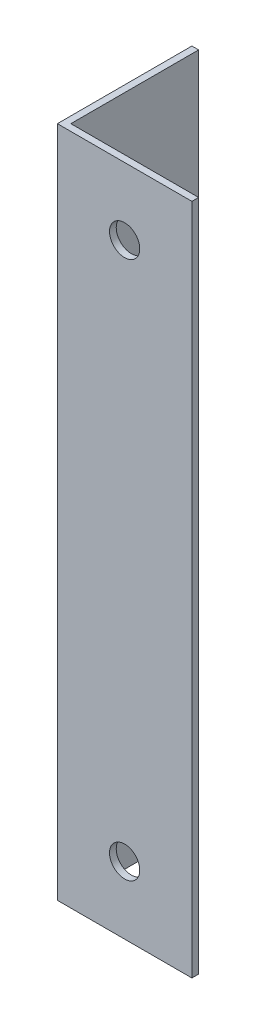
from build123d import *

# Parameters (mm, degrees)
EXTRUDE_1_DEPTH     = 100
SKETCH_2_R          = 2.25
CUT_EXTRUDE_1_DEPTH = 2
SKETCH_3_R          = 2.25
CUT_EXTRUDE_2_DEPTH = 2


with BuildPart() as part:
    # Эскиз1 → Бобышка-Вытянуть1 (new body)
    with BuildSketch(Plane(origin=(0, 0, 0), x_dir=(1, 0, 0), z_dir=(0, 1, 0))):
        Polygon((0, 0), (0, 20), (1, 20), (1, 1), (20, 1), (20, 0), align=None)
    extrude(amount=EXTRUDE_1_DEPTH)

    # Эскиз2 → Вырез-Вытянуть1 (cut, through all)
    with BuildSketch(Plane(origin=(0, 0, -1), x_dir=(-1, 0, 0), z_dir=(0, 0, -1))):
        with Locations((-10, 10)):
            Circle(SKETCH_2_R)
        with Locations((-10, 90)):
            Circle(SKETCH_2_R)
    extrude(amount=-CUT_EXTRUDE_1_DEPTH, mode=Mode.SUBTRACT)

    # Эскиз3 → Вырез-Вытянуть2 (cut, through all)
    with BuildSketch(Plane(origin=(1, 0, 0), x_dir=(0, 0, -1), z_dir=(1, 0, 0))):
        with Locations((10.5, 9.5)):
            Circle(SKETCH_3_R)
    extrude(amount=-CUT_EXTRUDE_2_DEPTH, mode=Mode.SUBTRACT)


solid = part.part
